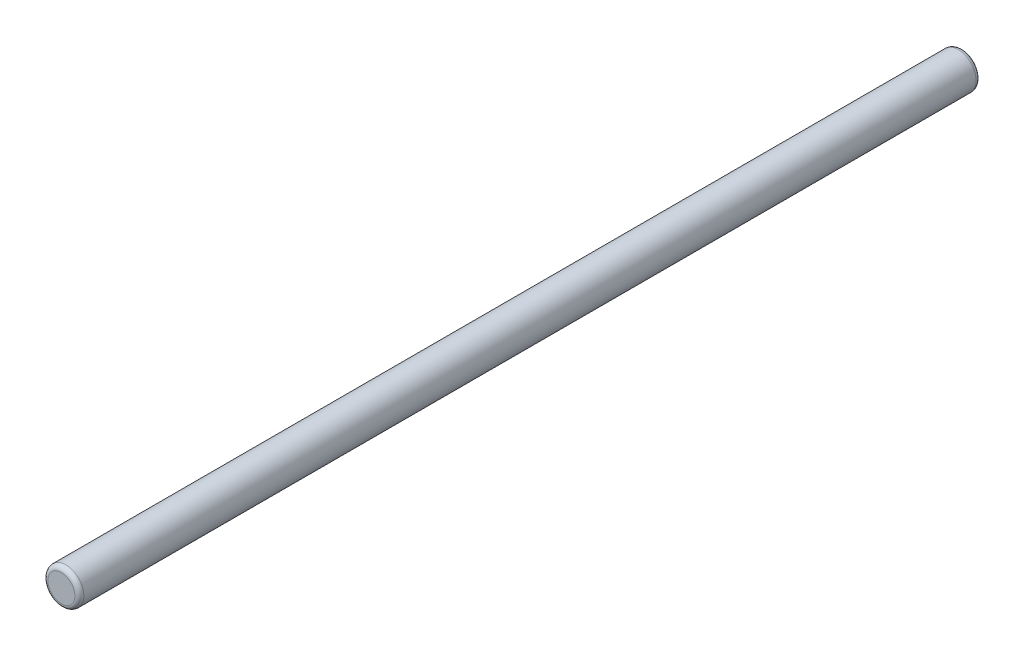
from build123d import *

# Parameters (mm, degrees)
SKIZZE1_R                       = 4
AUFSATZ_LINEAR_AUSTRAGEN1_DEPTH = 200
VERRUNDUNG1_R                   = 1


with BuildPart() as part:
    # Skizze1 → Aufsatz-Linear austragen1 (new body)
    with BuildSketch(Plane.XY):
        Circle(SKIZZE1_R)
    extrude(amount=AUFSATZ_LINEAR_AUSTRAGEN1_DEPTH)

    # Verrundung1
    verrundung1_edges = [part.edges().sort_by_distance(p)[0] for p in [
        (-4, 0, 0),
        (-4, 0, 200),
    ]]
    fillet(verrundung1_edges, radius=VERRUNDUNG1_R)


solid = part.part
